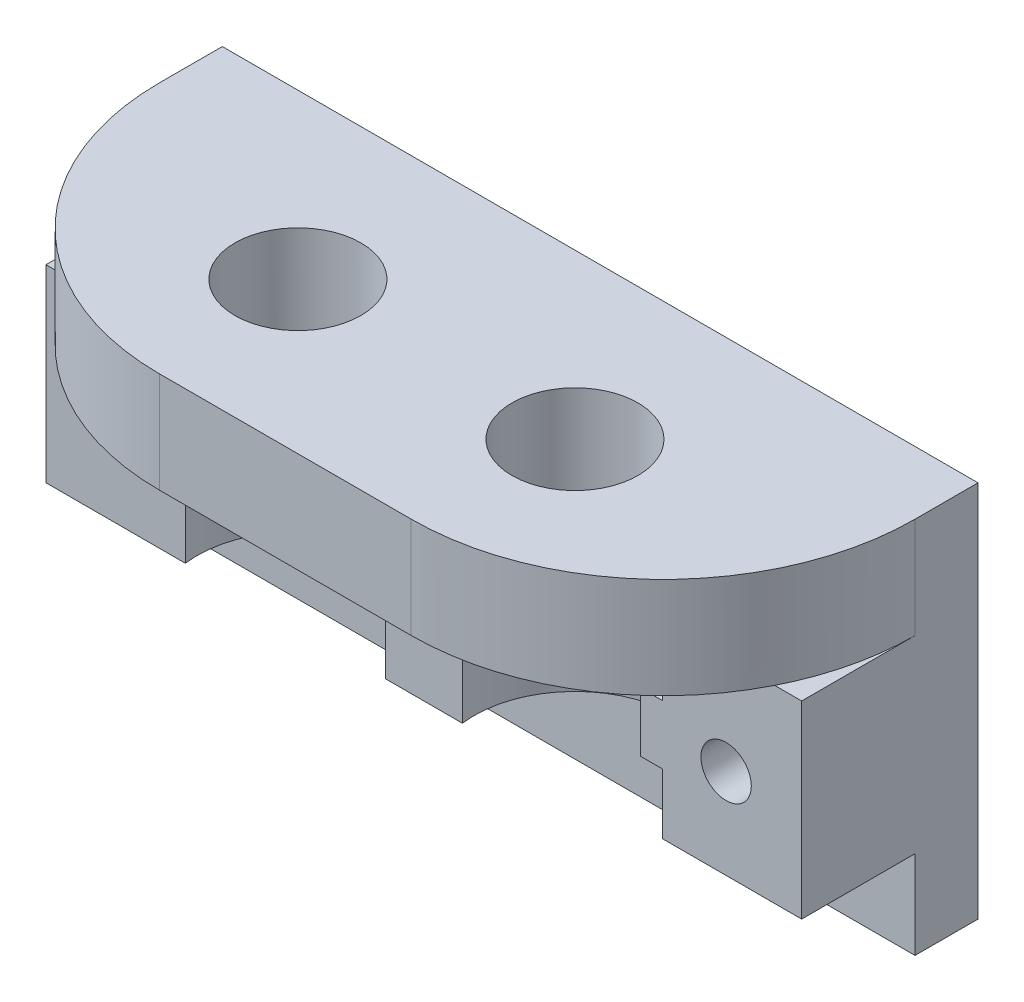
from build123d import *

# Parameters (mm, degrees)
SCHIZZO1_W                   = 60
SCHIZZO1_H                   = 30
ESTRUSIONE_ESTRUSIONE1_DEPTH = 5
SCHIZZO2_W                   = 60
SCHIZZO2_H                   = 8
ESTRUSIONE_ESTRUSIONE2_DEPTH = 20
SCHIZZO3_R                   = 5
TAGLIO_ESTRUSIONE1_DEPTH     = 8
RACCORDO1_R                  = 20
SCHIZZO4_W                   = 60
SCHIZZO4_H                   = 15
ESTRUSIONE_ESTRUSIONE3_DEPTH = 10
SCHIZZO6_R                   = 8
TAGLIO_ESTRUSIONE2_DEPTH     = 15
SCHIZZO8_W                   = 60
SCHIZZO8_H                   = 4.7
ESTRUSIONE_ESTRUSIONE4_DEPTH = 10
SCHIZZO9_R                   = 6.3
TAGLIO_ESTRUSIONE3_DEPTH     = 5
SCHIZZO10_R                  = 2
TAGLIO_ESTRUSIONE4_DEPTH     = 16
SCHIZZO11_W                  = 60
SCHIZZO11_H                  = 15
TAGLIO_ESTRUSIONE5_DEPTH     = 1


with BuildPart() as part:
    # Schizzo1 → Estrusione-Estrusione1 (new body)
    with BuildSketch(Plane.XY):
        Rectangle(SCHIZZO1_W, SCHIZZO1_H)
    extrude(amount=ESTRUSIONE_ESTRUSIONE1_DEPTH)

    # Schizzo2 → Estrusione-Estrusione2 (add)
    with BuildSketch(Plane.XY.offset(5)):
        with Locations((0, 11)):
            Rectangle(SCHIZZO2_W, SCHIZZO2_H)
    extrude(amount=ESTRUSIONE_ESTRUSIONE2_DEPTH)

    # Schizzo3 → Taglio-Estrusione1 (cut)
    with BuildSketch(Plane(origin=(0, 15, 0), x_dir=(1, 0, 0), z_dir=(0, 1, 0))):
        with Locations((11, -13)):
            Circle(SCHIZZO3_R)
        with Locations((-11, -13)):
            Circle(SCHIZZO3_R)
    extrude(amount=-TAGLIO_ESTRUSIONE1_DEPTH, mode=Mode.SUBTRACT)

    # Raccordo1
    raccordo1_edges = [part.edges().sort_by_distance(p)[0] for p in [
        (30, 11, 25),
        (-30, 11, 25),
    ]]
    fillet(raccordo1_edges, radius=RACCORDO1_R)

    # Schizzo4 → Estrusione-Estrusione3 (add)
    with BuildSketch(Plane.XY.offset(5)):
        with Locations((0, -0.5)):
            Rectangle(SCHIZZO4_W, SCHIZZO4_H)
    extrude(amount=ESTRUSIONE_ESTRUSIONE3_DEPTH)

    # Schizzo6 → Taglio-Estrusione2 (cut)
    with BuildSketch(Plane.XZ.offset(8)):
        with Locations((-11, 13)):
            Circle(SCHIZZO6_R)
        with Locations((11, 13)):
            Circle(SCHIZZO6_R)
    extrude(amount=-TAGLIO_ESTRUSIONE2_DEPTH, mode=Mode.SUBTRACT)

    # Schizzo8 → Estrusione-Estrusione4 (add)
    with BuildSketch(Plane.XY.offset(15)):
        with Locations((0, -0.85)):
            Rectangle(SCHIZZO8_W, SCHIZZO8_H)
    extrude(amount=-ESTRUSIONE_ESTRUSIONE4_DEPTH)

    # Schizzo9 → Taglio-Estrusione3 (cut)
    with BuildSketch(Plane.XZ.offset(3.2)):
        with Locations((-11, 13)):
            Circle(SCHIZZO9_R)
        with Locations((11, 13)):
            Circle(SCHIZZO9_R)
    extrude(amount=-TAGLIO_ESTRUSIONE3_DEPTH, mode=Mode.SUBTRACT)

    # Schizzo10 → Taglio-Estrusione4 (cut, through all)
    with BuildSketch(Plane.XY.offset(15)):
        with Locations((0, -0.85)):
            Circle(SCHIZZO10_R)
        with Locations((24, -0.85)):
            Circle(SCHIZZO10_R)
        with Locations((-24, -0.85)):
            Circle(SCHIZZO10_R)
    extrude(amount=-TAGLIO_ESTRUSIONE4_DEPTH, mode=Mode.SUBTRACT)

    # Schizzo11 → Taglio-Estrusione5 (cut)
    with BuildSketch(Plane.XY.offset(15)):
        with Locations((0, -0.5)):
            Rectangle(SCHIZZO11_W, SCHIZZO11_H)
    extrude(amount=-TAGLIO_ESTRUSIONE5_DEPTH, mode=Mode.SUBTRACT)


solid = part.part
